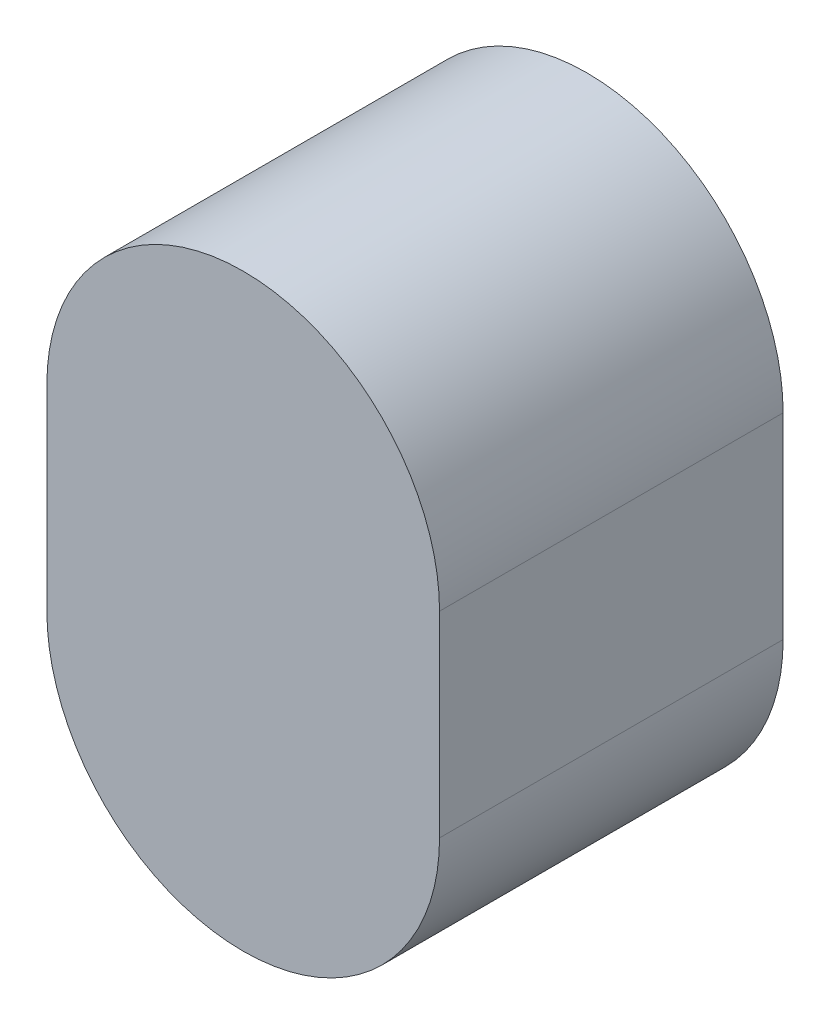
from build123d import *

# Parameters (mm, degrees)
BOSS_EXTRUDE1_DEPTH = 7


with BuildPart() as part:
    # Sketch1 → Boss-Extrude1 (new body)
    with BuildSketch(Plane.XY):
        with BuildLine():
            Line((4, 0), (4, -4))
            ThreePointArc((4, -4), (0, -8), (-4, -4))
            Line((-4, -4), (-4, 0))
            ThreePointArc((-4, 0), (0, 4), (4, 0))
        make_face()
    extrude(amount=BOSS_EXTRUDE1_DEPTH)


solid = part.part
